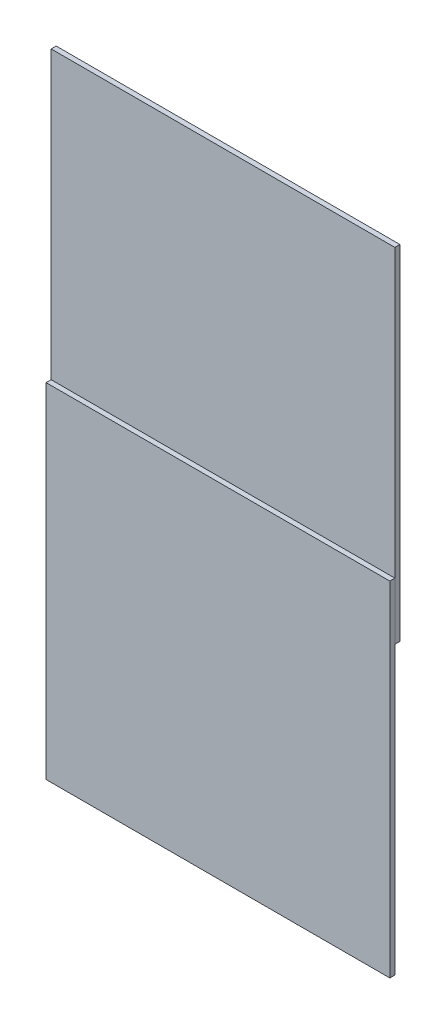
from build123d import *

# Parameters (mm, degrees)
SKIZZE2_W                       = 150
SKIZZE2_H                       = 150
AUFSATZ_LINEAR_AUSTRAGEN1_DEPTH = 2.2
SKIZZE3_W                       = 150
SKIZZE3_H                       = 150
AUFSATZ_LINEAR_AUSTRAGEN3_DEPTH = 2.2
SKIZZE5_R                       = 12.5
AUFSATZ_LINEAR_AUSTRAGEN4_DEPTH = 25


with BuildPart() as part:
    # Skizze2 → Aufsatz-Linear austragen1 (new body)
    with BuildSketch(Plane.XY):
        with Locations((75, -75)):
            Rectangle(SKIZZE2_W, SKIZZE2_H)
    extrude(amount=AUFSATZ_LINEAR_AUSTRAGEN1_DEPTH)


with BuildPart() as body_2:
    # Skizze3 → Aufsatz-Linear austragen3 (new body)
    with BuildSketch(Plane(origin=(0, 0, 0), x_dir=(-1, 0, 0), z_dir=(0, 0, -1))):
        with Locations((-75, 50)):
            Rectangle(SKIZZE3_W, SKIZZE3_H)
    extrude(amount=AUFSATZ_LINEAR_AUSTRAGEN3_DEPTH)


with BuildPart() as body_3:
    # Skizze5 → Aufsatz-Linear austragen4 (new body)
    with BuildSketch(Plane(origin=(0, -25, 0), x_dir=(-1, 0, 0), z_dir=(0, -1, 0))):
        with Locations(Location((-92.405874956, 14.7, 0), (0, 0, 180))):  # turned: the seam where the file's is
            Circle(SKIZZE5_R)
    extrude(amount=-AUFSATZ_LINEAR_AUSTRAGEN4_DEPTH)


solid = Compound([part.part, body_2.part, body_3.part])
